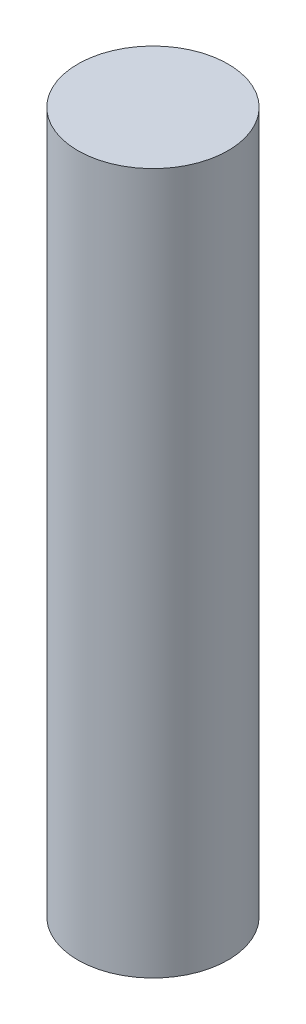
from build123d import *

# Parameters (mm, degrees)
SKETCH2_R           = 1.5
BOSS_EXTRUDE1_DEPTH = 14


with BuildPart() as part:
    # Sketch2 → Boss-Extrude1 (new body)
    with BuildSketch(Plane(origin=(0, 0, 0), x_dir=(1, 0, 0), z_dir=(0, 1, 0))):
        Circle(SKETCH2_R)
    extrude(amount=BOSS_EXTRUDE1_DEPTH)


solid = part.part
